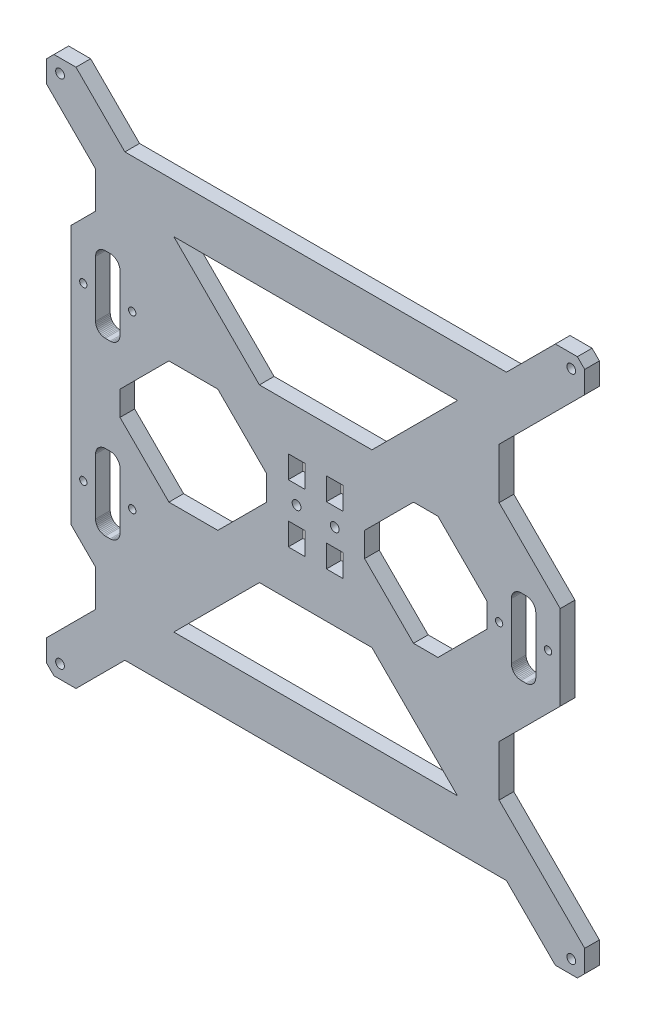
from build123d import *

# Parameters (mm, degrees)
MODEL_R                  = 1.8
MODEL_R_2                = 1.5
MODEL_W                  = 6.800001917
MODEL_H                  = 9.1999977
MODEL_H_2                = 9.199995837
MODEL_W_2                = 6.800001918
RESSALTO_EXTRUS_O1_DEPTH = 6


with BuildPart() as part:
    # Model → Ressalto-extrusão1 (new body)
    with BuildSketch(Plane.XY):
        Polygon((36.036846392, 16.810604115), (56.036838792, 36.810596515), (212.036788872, 36.810596515), (232.036781272, 16.810604115), (241.036779592, 16.810604115), (244.036778632, 19.810603155), (244.036778632, 28.810601475), (209.036791032, 63.810589075), (209.036791032, 84.536708322), (234.036781832, 109.536699122), (234.036781832, 144.113804163), (209.036791032, 169.113794963), (209.036791032, 189.810548755), (244.036778632, 224.810536355), (244.036778632, 233.810534675), (241.036779592, 236.810533715), (232.036781272, 236.810533715), (212.036788872, 216.810541315), (56.036838792, 216.810541315), (36.036846392, 236.810533715), (27.036848072, 236.810533715), (24.036849032, 233.810534675), (24.036849032, 224.810536355), (44.036842632, 204.810542755), (44.036842632, 189.810548755), (34.036845832, 179.810551955), (34.036845832, 73.810585875), (44.036842632, 63.810589075), (44.036842632, 48.810595075), (24.036849032, 28.810601475), (24.036849032, 19.810603155), (27.036848072, 16.810604115), align=None)
        with Locations((126.233233316, 126.844412715)):
            Circle(MODEL_R, mode=Mode.SUBTRACT)
        with Locations((29.526465016, 231.320917731)):
            Circle(MODEL_R, mode=Mode.SUBTRACT)
        with Locations((39.036844232, 161.810557715)):
            Circle(MODEL_R_2, mode=Mode.SUBTRACT)
        with Locations((59.036837832, 161.810557715)):
            Circle(MODEL_R_2, mode=Mode.SUBTRACT)
        with Locations((29.526465016, 22.300220099)):
            Circle(MODEL_R, mode=Mode.SUBTRACT)
        with Locations((39.036844232, 91.810580115)):
            Circle(MODEL_R_2, mode=Mode.SUBTRACT)
        with Locations((59.036837832, 91.810580115)):
            Circle(MODEL_R_2, mode=Mode.SUBTRACT)
        with Locations((238.547162648, 231.320917731)):
            Circle(MODEL_R, mode=Mode.SUBTRACT)
        with Locations((238.547162648, 22.300220099)):
            Circle(MODEL_R, mode=Mode.SUBTRACT)
        with Locations((209.036789832, 126.810568915)):
            Circle(MODEL_R_2, mode=Mode.SUBTRACT)
        with Locations((229.036783432, 126.810568915)):
            Circle(MODEL_R_2, mode=Mode.SUBTRACT)
        with Locations((141.840394347, 126.844412715)):
            Circle(MODEL_R, mode=Mode.SUBTRACT)
        Polygon((46.506108112, 107.506093223), (46.036841992, 107.274676782), (45.601796415, 106.983988621), (45.208415132, 106.639002495), (44.863429006, 106.245621212), (44.572740845, 105.810575635), (44.341324404, 105.341309515), (44.173139283, 104.845852124), (44.071063175, 104.332680877), (44.036842632, 103.810576275), (44.036842632, 80.810583635), (44.071063175, 80.288479033), (44.173139283, 79.775307786), (44.341324404, 79.279850395), (44.572740845, 78.810584275), (44.863429006, 78.375538698), (45.208415132, 77.982157415), (45.601796415, 77.637171289), (46.036841992, 77.346483128), (46.506108112, 77.115066688), (47.001565503, 76.946881566), (47.51473675, 76.844805459), (48.036841352, 76.810584915), (50.036840712, 76.810584915), (50.558945313, 76.844805459), (51.072116561, 76.946881566), (51.567573951, 77.115066688), (52.036840072, 77.346483128), (52.471885649, 77.637171289), (52.865266931, 77.982157415), (53.210253057, 78.375538698), (53.500941218, 78.810584275), (53.732357659, 79.279850395), (53.90054278, 79.775307786), (54.002618888, 80.288479033), (54.036839432, 80.810583635), (54.036839432, 103.810576275), (54.002618888, 104.332680877), (53.90054278, 104.845852124), (53.732357659, 105.341309515), (53.500941218, 105.810575635), (53.210253057, 106.245621212), (52.865266931, 106.639002495), (52.471885649, 106.983988621), (52.036840072, 107.274676782), (51.567573951, 107.506093223), (51.072116561, 107.674278344), (50.558945313, 107.776354452), (50.036840712, 107.810574995), (48.036841352, 107.810574995), (47.51473675, 107.776354452), (47.001565503, 107.674278344), align=None, mode=Mode.SUBTRACT)
        Polygon((216.506053712, 141.368958779), (216.036787592, 141.137542339), (215.601742015, 140.846854178), (215.208360732, 140.501868052), (214.863374606, 140.108486769), (214.572686445, 139.673441192), (214.341270004, 139.204175072), (214.173084883, 138.708717681), (214.071008775, 138.195546434), (214.036788232, 137.673441832), (214.036788232, 114.673449192), (214.071008775, 114.15134459), (214.173084883, 113.638173343), (214.341270004, 113.142715952), (214.572686445, 112.673449832), (214.863374606, 112.238404255), (215.208360732, 111.845022972), (215.601742015, 111.500036846), (216.036787592, 111.209348685), (216.506053712, 110.977932244), (217.001511103, 110.809747123), (217.51468235, 110.707671015), (218.036786952, 110.673450472), (220.036786312, 110.673450472), (220.558890914, 110.707671015), (221.072062161, 110.809747123), (221.567519551, 110.977932244), (222.036785672, 111.209348685), (222.471831249, 111.500036846), (222.865212531, 111.845022972), (223.210198657, 112.238404255), (223.500886818, 112.673449832), (223.732303259, 113.142715952), (223.90048838, 113.638173343), (224.002564488, 114.15134459), (224.036785032, 114.673449192), (224.036785032, 137.673441832), (224.002564488, 138.195546434), (223.90048838, 138.708717681), (223.732303259, 139.204175072), (223.500886818, 139.673441192), (223.210198657, 140.108486769), (222.865212531, 140.501868052), (222.471831249, 140.846854178), (222.036785672, 141.137542339), (221.567519551, 141.368958779), (221.072062161, 141.537143901), (220.558890914, 141.639220008), (220.036786312, 141.673440552), (218.036786952, 141.673440552), (217.51468235, 141.639220008), (217.001511103, 141.537143901), align=None, mode=Mode.SUBTRACT)
        Polygon((53.90054278, 174.852866618), (53.732357659, 175.348324009), (53.500941218, 175.817590129), (53.210253057, 176.252635706), (52.865266931, 176.646016989), (52.471885649, 176.991003115), (52.036840072, 177.281691276), (51.567573951, 177.513107716), (51.072116561, 177.681292838), (50.558945313, 177.783368945), (50.036840712, 177.817589489), (48.036841352, 177.817589489), (47.51473675, 177.783368945), (47.001565503, 177.681292838), (46.506108112, 177.513107716), (46.036841992, 177.281691276), (45.601796415, 176.991003115), (45.208415132, 176.646016989), (44.863429006, 176.252635706), (44.572740845, 175.817590129), (44.341324404, 175.348324009), (44.173139283, 174.852866618), (44.071063175, 174.339695371), (44.036842632, 173.817590769), (44.036842632, 150.817598129), (44.071063175, 150.295493527), (44.173139283, 149.78232228), (44.341324404, 149.286864889), (44.572740845, 148.817598769), (44.863429006, 148.382553192), (45.208415132, 147.989171909), (45.601796415, 147.644185783), (46.036841992, 147.353497622), (46.506108112, 147.122081181), (47.001565503, 146.95389606), (47.51473675, 146.851819952), (48.036841352, 146.817599409), (50.036840712, 146.817599409), (50.558945313, 146.851819952), (51.072116561, 146.95389606), (51.567573951, 147.122081181), (52.036840072, 147.353497622), (52.471885649, 147.644185783), (52.865266931, 147.989171909), (53.210253057, 148.382553192), (53.500941218, 148.817598769), (53.732357659, 149.286864889), (53.90054278, 149.78232228), (54.002618888, 150.295493527), (54.036839432, 150.817598129), (54.036839432, 173.817590769), (54.002618888, 174.339695371), align=None, mode=Mode.SUBTRACT)
        Polygon((76.036834792, 196.810545315), (192.036792872, 196.810545315), (157.036805272, 161.810557715), (111.036822392, 161.810557715), align=None, mode=Mode.SUBTRACT)
        Polygon((114.036820232, 131.810567315), (114.036820232, 121.810570515), (94.036826632, 101.810576915), (74.036833032, 101.810576915), (54.036839432, 121.810570515), (54.036839432, 131.810567315), (74.036833032, 151.810560915), (94.036826632, 151.810560915), align=None, mode=Mode.SUBTRACT)
        Polygon((204.036791432, 131.810567315), (204.036791432, 121.810570515), (184.036797832, 101.810576915), (174.036801032, 101.810576915), (154.036807432, 121.810570515), (154.036807432, 131.810567315), (174.036801032, 151.810560915), (184.036797832, 151.810560915), align=None, mode=Mode.SUBTRACT)
        Polygon((111.036822392, 91.810580115), (76.036834792, 56.810592515), (192.036792872, 56.810592515), (157.036805272, 91.810580115), align=None, mode=Mode.SUBTRACT)
        with Locations((126.234958166, 114.944160317)):
            Rectangle(MODEL_W, MODEL_H, mode=Mode.SUBTRACT)
        with Locations((126.234958166, 138.744151147)):
            Rectangle(MODEL_W, MODEL_H_2, mode=Mode.SUBTRACT)
        with Locations((141.838669498, 114.944160317)):
            Rectangle(MODEL_W_2, MODEL_H, mode=Mode.SUBTRACT)
        with Locations((141.838669498, 138.744151147)):
            Rectangle(MODEL_W_2, MODEL_H_2, mode=Mode.SUBTRACT)
    extrude(amount=RESSALTO_EXTRUS_O1_DEPTH)


solid = part.part
